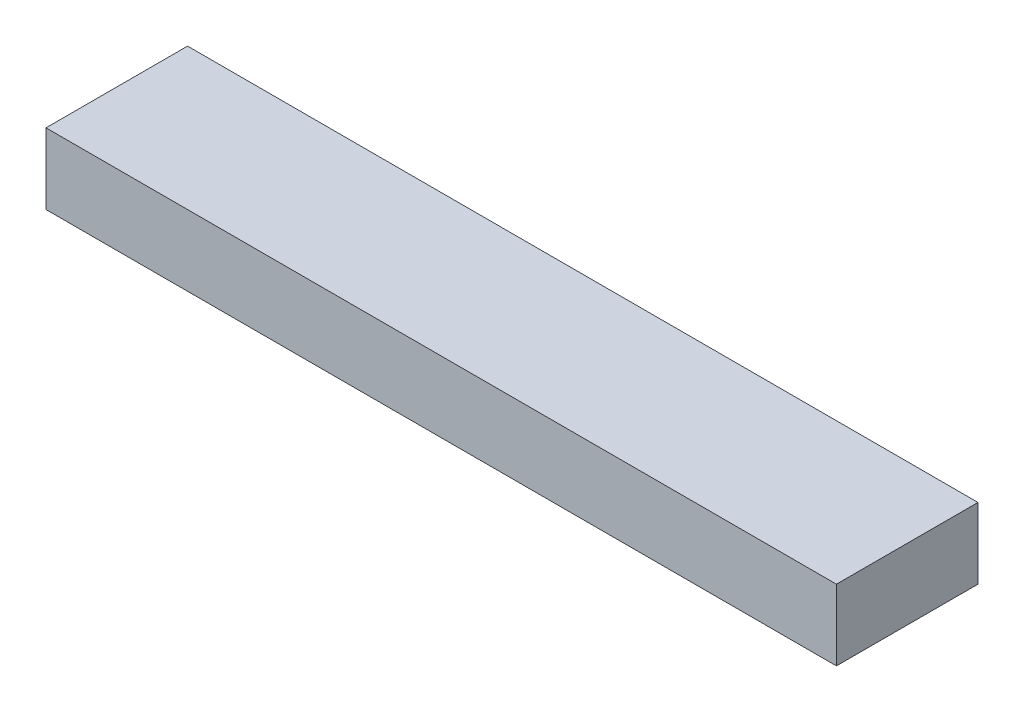
from build123d import *

# Parameters (mm, degrees)
SKETCH1_W           = 212.725
SKETCH1_H           = 38.1
BOSS_EXTRUDE1_DEPTH = 19.05


with BuildPart() as part:
    # Sketch1 → Boss-Extrude1 (new body)
    with BuildSketch(Plane(origin=(0, 0, 0), x_dir=(1, 0, 0), z_dir=(0, 1, 0))):
        with Locations((106.3625, 19.05)):
            Rectangle(SKETCH1_W, SKETCH1_H)
    extrude(amount=BOSS_EXTRUDE1_DEPTH)


solid = part.part
